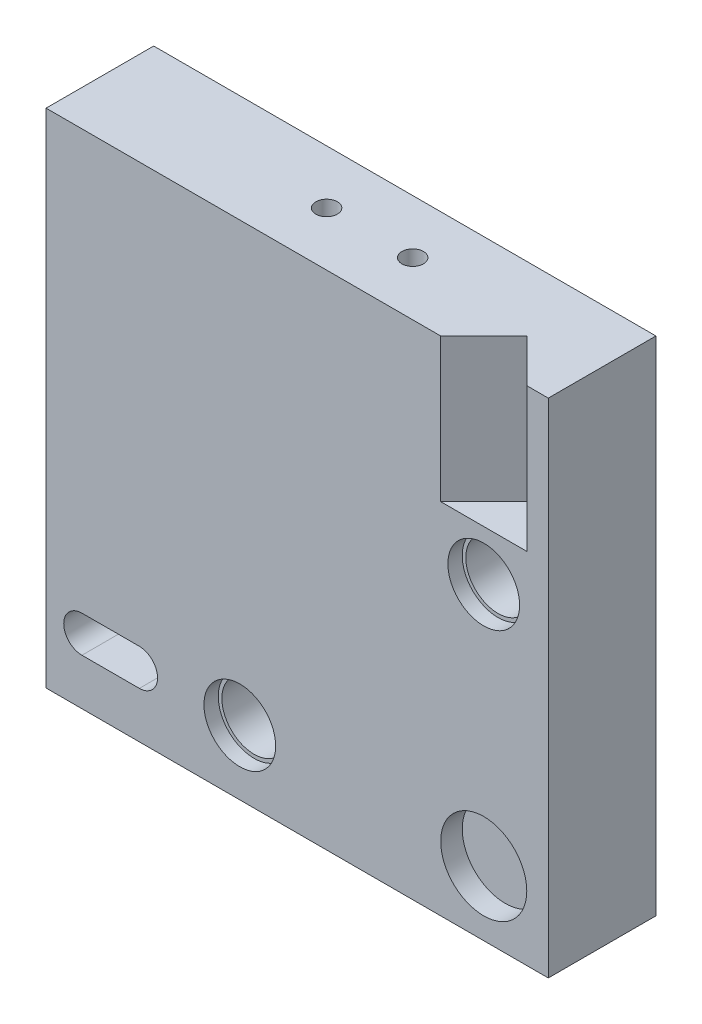
from build123d import *

# Parameters (mm, degrees)
SKETCH1_W           = 35
SKETCH1_H           = 35
BOSS_EXTRUDE1_DEPTH = 7.5
SKETCH2_W           = 24
SKETCH2_H           = 13
CUT_EXTRUDE2_DEPTH  = 5
SKETCH10_R          = 0.75
CUT_EXTRUDE7_DEPTH  = 7
SKETCH5_R           = 2.5
CUT_EXTRUDE11_DEPTH = 1
SKETCH11_R          = 2.25
CUT_EXTRUDE12_DEPTH = 5
CUT_EXTRUDE13_DEPTH = 10
CUT_EXTRUDE14_DEPTH = 10
CUT_EXTRUDE15_DEPTH = 4
BOSS_EXTRUDE2_DEPTH = 10
SKETCH17_R          = 3
CUT_EXTRUDE16_DEPTH = 1.5


with BuildPart() as part:
    # Sketch1 → Boss-Extrude1 (new body)
    with BuildSketch(Plane.XY):
        with Locations((-0.233740073, -3.509910016)):
            Rectangle(SKETCH1_W, SKETCH1_H)
    extrude(amount=BOSS_EXTRUDE1_DEPTH)

    # Sketch2 → Cut-Extrude2 (cut)
    with BuildSketch(Plane(origin=(0, 0, 0), x_dir=(-1, 0, 0), z_dir=(0, 0, -1))):
        with Locations((5.733740073, -3.509910016)):
            Rectangle(SKETCH2_W, SKETCH2_H)
    extrude(amount=-CUT_EXTRUDE2_DEPTH, mode=Mode.SUBTRACT)

    # Sketch10 → Cut-Extrude7 (cut)
    with BuildSketch(Plane(origin=(0, 13.990089984, 0), x_dir=(1, 0, 0), z_dir=(0, 1, 0))):
        with Locations((4.066259927, -3.75)):
            Circle(SKETCH10_R)
        with Locations((-1.933740073, -3.75)):
            Circle(SKETCH10_R)
    extrude(amount=-CUT_EXTRUDE7_DEPTH, mode=Mode.SUBTRACT)

    # Sketch5 → Cut-Extrude11 (cut)
    with BuildSketch(Plane.XY.offset(7.5)):
        with Locations((12.766259927, 0.490089984)):
            Circle(SKETCH5_R)
        with Locations((-4.233740073, -16.509910016)):
            Circle(SKETCH5_R)
    extrude(amount=-CUT_EXTRUDE11_DEPTH, mode=Mode.SUBTRACT)

    # Sketch11 → Cut-Extrude12 (cut)
    with BuildSketch(Plane.XY.offset(6.5)):
        with Locations((-4.233740073, -16.509910016)):
            Circle(SKETCH11_R)
        with Locations((12.766259927, 0.490089984)):
            Circle(SKETCH11_R)
    extrude(amount=-CUT_EXTRUDE12_DEPTH, mode=Mode.SUBTRACT)

    # Sketch13 → Cut-Extrude13 (cut)
    with BuildSketch(Plane.XZ.offset(21.009910016)):
        Polygon((9.766259927, 7.5), (12.766259927, 4.5), (15.766259927, 7.5), align=None)
    extrude(amount=-CUT_EXTRUDE13_DEPTH, mode=Mode.SUBTRACT)

    # Sketch15 → Cut-Extrude14 (cut)
    with BuildSketch(Plane(origin=(0, 13.990089984, 0), x_dir=(1, 0, 0), z_dir=(0, 1, 0))):
        Polygon((9.766259927, -7.5), (12.766259927, -4.5), (15.766259927, -7.5), align=None)
    extrude(amount=-CUT_EXTRUDE14_DEPTH, mode=Mode.SUBTRACT)

    # Sketch4 → Cut-Extrude15 (cut)
    with BuildSketch(Plane.XY.offset(7.5)):
        with BuildLine():
            Line((-11.233740073, -15.239910016), (-15.233740073, -15.239910016))
            ThreePointArc((-15.233740073, -15.239910016), (-16.503740073, -16.509910016), (-15.233740073, -17.779910016))
            Line((-15.233740073, -17.779910016), (-11.233740073, -17.779910016))
            ThreePointArc((-11.233740073, -17.779910016), (-9.963740073, -16.509910016), (-11.233740073, -15.239910016))
        make_face()
    extrude(amount=-CUT_EXTRUDE15_DEPTH, mode=Mode.SUBTRACT)

    # Sketch16 → Boss-Extrude2 (add)
    with BuildSketch(Plane(origin=(0, -11.009910016, 0), x_dir=(-1, 0, 0), z_dir=(0, -1, 0))):
        Polygon((-9.766259927, -7.5), (-15.766259927, -7.5), (-12.766259927, -4.5), align=None)
    extrude(amount=BOSS_EXTRUDE2_DEPTH)

    # Sketch17 → Cut-Extrude16 (cut)
    with BuildSketch(Plane.XY.offset(7.5)):
        with Locations((12.766259927, -16.509910016)):
            Circle(SKETCH17_R)
    extrude(amount=-CUT_EXTRUDE16_DEPTH, mode=Mode.SUBTRACT)


solid = part.part
